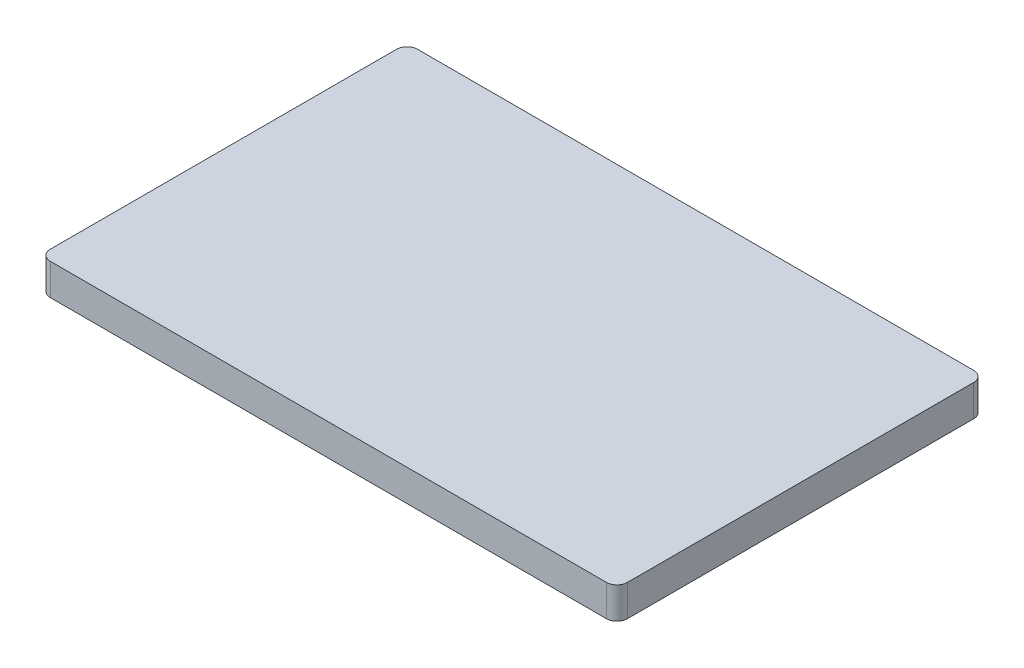
from build123d import *

# Parameters (mm, degrees)
EXTRUDE_1_DEPTH = 3


with BuildPart() as part:
    # 草图1 → 凸台-拉伸1 (new body)
    with BuildSketch(Plane(origin=(0, 0, 0), x_dir=(1, 0, 0), z_dir=(0, 1, 0))):
        with BuildLine():
            Line((26.5, -17.5), (-26.5, -17.5))
            ThreePointArc((-26.5, -17.5), (-27.207106781, -17.207106781), (-27.5, -16.5))
            Line((-27.5, -16.5), (-27.5, 16.5))
            ThreePointArc((-27.5, 16.5), (-27.207106781, 17.207106781), (-26.5, 17.5))
            Line((-26.5, 17.5), (26.5, 17.5))
            ThreePointArc((26.5, 17.5), (27.207106781, 17.207106781), (27.5, 16.5))
            Line((27.5, 16.5), (27.5, -16.5))
            ThreePointArc((27.5, -16.5), (27.207106781, -17.207106781), (26.5, -17.5))
        make_face()
    extrude(amount=EXTRUDE_1_DEPTH)


solid = part.part
